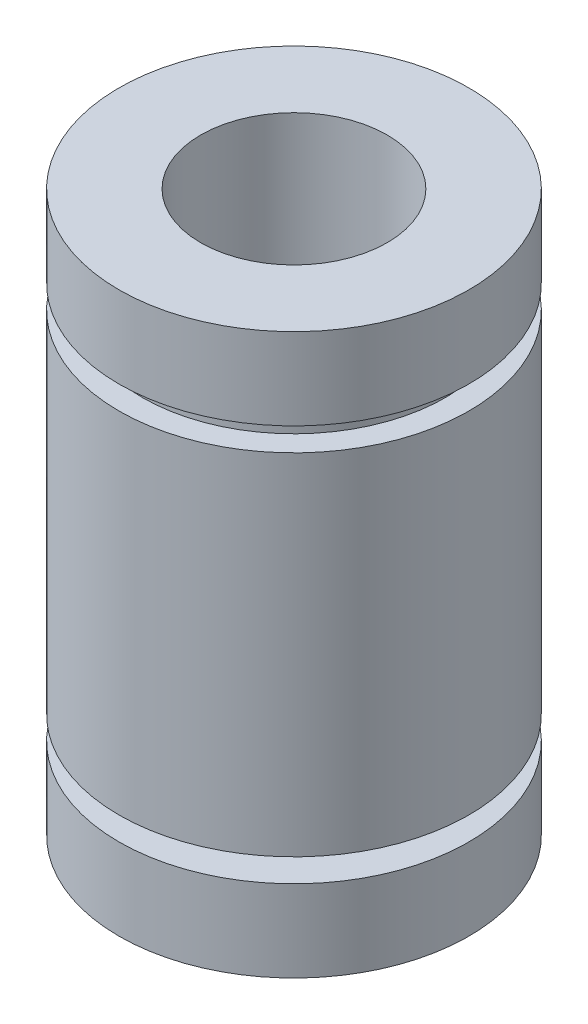
from build123d import *


with BuildPart() as part:
    # Croquis3 → Revolución2 (revolve)
    with BuildSketch(Plane(origin=(0, 0, 0), x_dir=(0, 0, -1), z_dir=(1, 0, 0))):
        Polygon((-7.5, 0), (-4, 0), (-4, -24), (-7.5, -24), (-7.5, -20.5), (-5.75, -20.5), (-5.75, -19.5), (-7.5, -19.5), (-7.5, -4.5), (-6.5, -4.5), (-6.5, -3.5), (-7.5, -3.5), align=None)
    revolve(axis=Axis((0, 0, 0), (0, -1, 0)))


solid = part.part
